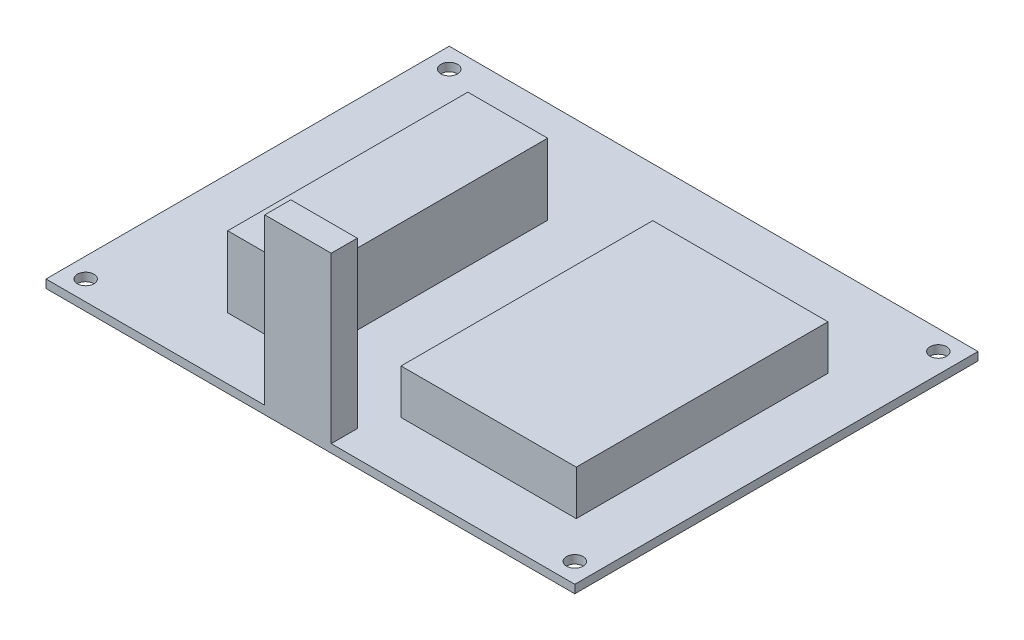
from build123d import *

# Parameters (mm, degrees)
SKETCH1_W           = 101.6
SKETCH1_H           = 77.47
BOSS_EXTRUDE1_DEPTH = 1.5875
SKETCH2_R           = 1.6002
CUT_EXTRUDE1_DEPTH  = 2.54
SKETCH3_W           = 12.769362992
SKETCH3_H           = 5.005824016
BOSS_EXTRUDE2_DEPTH = 33.274
SKETCH4_W           = 33.664684251
SKETCH4_H           = 48.368799212
BOSS_EXTRUDE3_DEPTH = 10.16
SKETCH5_W           = 15.332321875
SKETCH5_H           = 46.138952111
BOSS_EXTRUDE4_DEPTH = 15.24


with BuildPart() as part:
    # Sketch1 → Boss-Extrude1 (new body)
    with BuildSketch(Plane(origin=(0, 0, 0), x_dir=(1, 0, 0), z_dir=(0, 1, 0))):
        with Locations((-46.570976536, 16.383405637)):
            Rectangle(SKETCH1_W, SKETCH1_H)
    extrude(amount=BOSS_EXTRUDE1_DEPTH)

    # Sketch2 → Cut-Extrude1 (cut)
    with BuildSketch(Plane(origin=(0, 1.5875, 0), x_dir=(1, 0, 0), z_dir=(0, 1, 0))):
        with Locations((-93.560976536, -18.541594363)):
            Circle(SKETCH2_R)
        with Locations((-93.560976536, 51.308405637)):
            Circle(SKETCH2_R)
        with Locations((0.419023464, 51.308405637)):
            Circle(SKETCH2_R)
        with Locations((0.419023464, -18.541594363)):
            Circle(SKETCH2_R)
    extrude(amount=-CUT_EXTRUDE1_DEPTH, mode=Mode.SUBTRACT)

    # Sketch3 → Boss-Extrude2 (add)
    with BuildSketch(Plane(origin=(0, 0, 0), x_dir=(1, 0, 0), z_dir=(0, 1, 0))):
        with Locations((-48.957170631, -19.848682355)):
            Rectangle(SKETCH3_W, SKETCH3_H)
    extrude(amount=BOSS_EXTRUDE2_DEPTH)

    # Sketch4 → Boss-Extrude3 (add)
    with BuildSketch(Plane(origin=(0, 0, 0), x_dir=(1, 0, 0), z_dir=(0, 1, 0))):
        with Locations((-23.385471389, 12.894993304)):
            Rectangle(SKETCH4_W, SKETCH4_H)
    extrude(amount=BOSS_EXTRUDE3_DEPTH)

    # Sketch5 → Boss-Extrude4 (add)
    with BuildSketch(Plane(origin=(0, 0, 0), x_dir=(1, 0, 0), z_dir=(0, 1, 0))):
        with Locations((-66.619550072, 12.54421879)):
            Rectangle(SKETCH5_W, SKETCH5_H)
    extrude(amount=BOSS_EXTRUDE4_DEPTH)


solid = part.part
